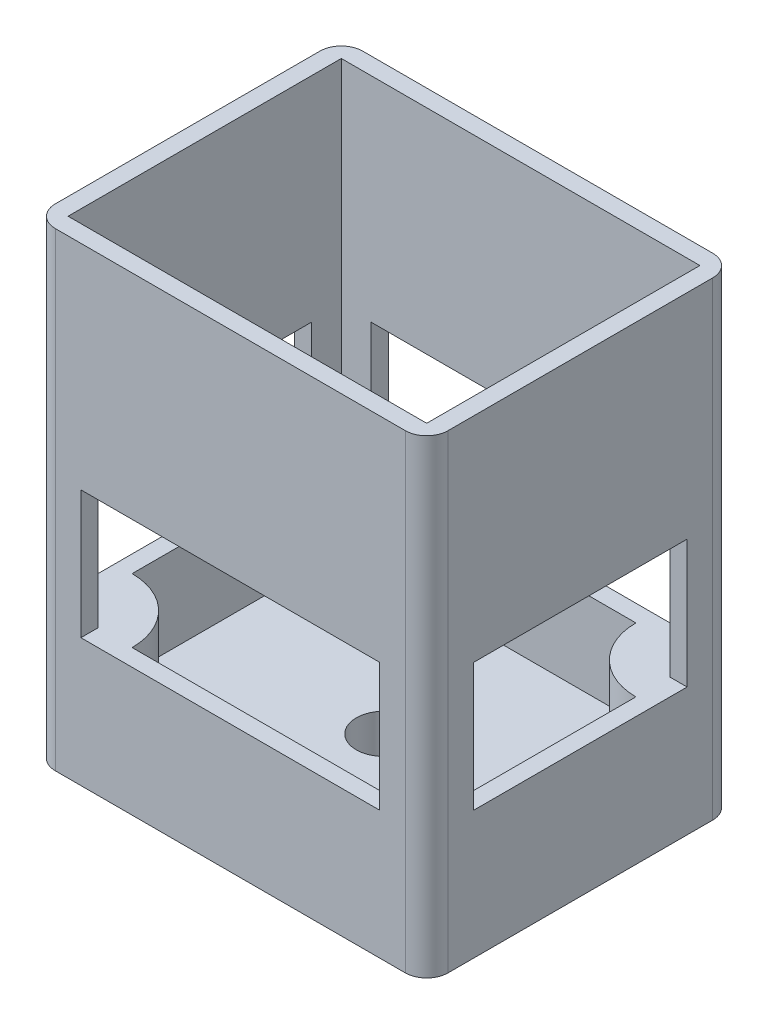
from build123d import *

# Parameters (mm, degrees)
SKETCH1_W           = 46
SKETCH1_H           = 36
SKETCH1_W_2         = 42
SKETCH1_H_2         = 32
BOSS_EXTRUDE1_DEPTH = 55
SKETCH2_W           = 42
SKETCH2_H           = 32
BOSS_EXTRUDE2_DEPTH = 5
FILLET1_R           = 2.5
BOSS_EXTRUDE3_DEPTH = 10
SKETCH3_W           = 25
SKETCH3_H           = 15
CUT_EXTRUDE1_DEPTH  = 47
SKETCH5_W           = 35
SKETCH5_H           = 15
CUT_EXTRUDE2_DEPTH  = 37
CUT_EXTRUDE3_REACH  = 7
SKETCH7_R           = 3.25


with BuildPart() as part:
    # Sketch1 → Boss-Extrude1 (new body)
    with BuildSketch(Plane(origin=(0, 0, 0), x_dir=(1, 0, 0), z_dir=(0, 1, 0))):
        Rectangle(SKETCH1_W, SKETCH1_H)
        Rectangle(SKETCH1_W_2, SKETCH1_H_2, mode=Mode.SUBTRACT)
    extrude(amount=BOSS_EXTRUDE1_DEPTH)

    # Sketch2 → Boss-Extrude2 (add)
    with BuildSketch(Plane.XZ):
        Rectangle(SKETCH2_W, SKETCH2_H)
    extrude(amount=-BOSS_EXTRUDE2_DEPTH)

    # Fillet1
    fillet1_edges = [part.edges().sort_by_distance(p)[0] for p in [
        (-23, 27.5, -18),
        (23, 27.5, -18),
        (23, 27.5, 18),
        (-23, 27.5, 18),
    ]]
    fillet(fillet1_edges, radius=FILLET1_R)

    # Sketch4 → Boss-Extrude3 (add)
    with BuildSketch(Plane(origin=(0, 5, 0), x_dir=(1, 0, 0), z_dir=(0, 1, 0))):
        with BuildLine():
            Line((-21, -16), (-13.5, -16))
            ThreePointArc((-13.5, -16), (-15.696699141, -10.696699141), (-21, -8.5))
            Line((-21, -8.5), (-21, -16))
        make_face()
        with BuildLine():
            Line((21, 16), (13.5, 16))
            ThreePointArc((13.5, 16), (15.696699141, 10.696699141), (21, 8.5))
            Line((21, 8.5), (21, 16))
        make_face()
    extrude(amount=BOSS_EXTRUDE3_DEPTH)

    # Sketch3 → Cut-Extrude1 (cut, through all)
    with BuildSketch(Plane(origin=(23, 0, -5), x_dir=(0, 0, 1), z_dir=(-1, 0, 0))):
        with Locations((5, 22.5)):
            Rectangle(SKETCH3_W, SKETCH3_H)
    extrude(amount=CUT_EXTRUDE1_DEPTH, mode=Mode.SUBTRACT)

    # Sketch5 → Cut-Extrude2 (cut, through all)
    with BuildSketch(Plane.XY.offset(18)):
        with Locations((0, 22.5)):
            Rectangle(SKETCH5_W, SKETCH5_H)
    extrude(amount=-CUT_EXTRUDE2_DEPTH, mode=Mode.SUBTRACT)

    # Sketch7 → Cut-Extrude3 (cut, up to next)
    with BuildSketch(Plane(origin=(0, 5, 0), x_dir=(1, 0, 0), z_dir=(0, 1, 0)), mode=Mode.PRIVATE) as cut_extrude3_sk1:
        Circle(SKETCH7_R)
    cut_extrude3_tool1 = extrude(cut_extrude3_sk1.sketch, amount=-CUT_EXTRUDE3_REACH, mode=Mode.PRIVATE) & part.part
    add(cut_extrude3_tool1.solids().sort_by_distance((0, 5, 0))[0], mode=Mode.SUBTRACT)


solid = part.part
